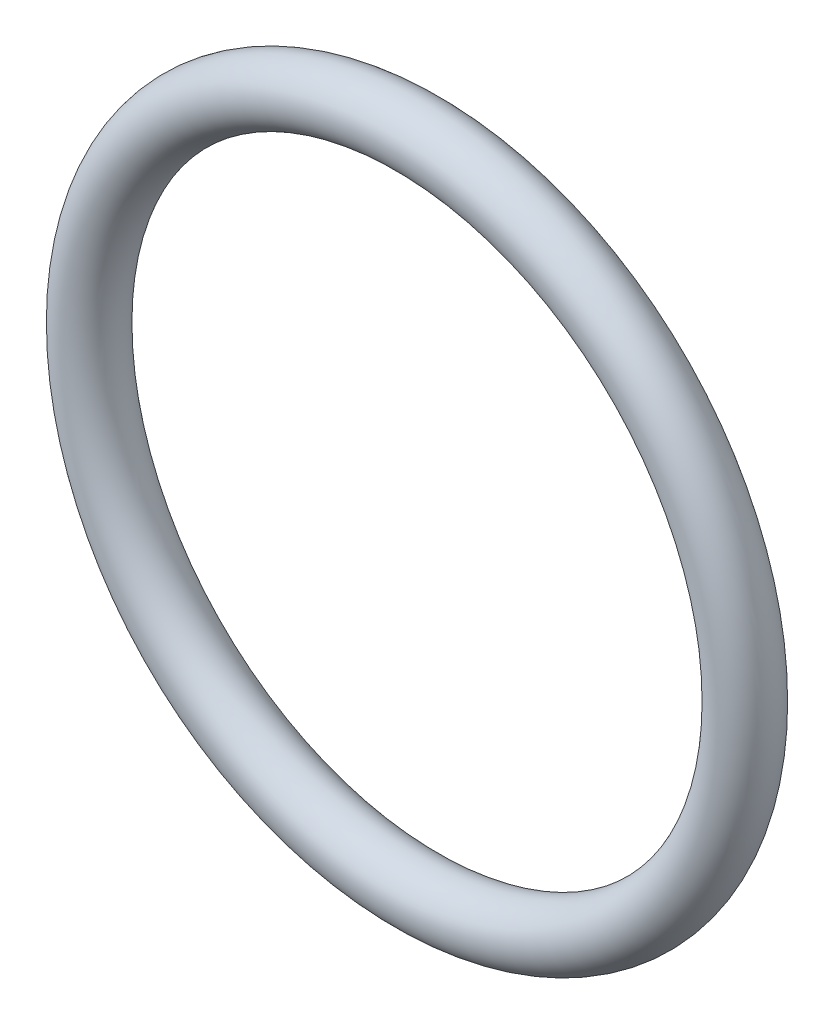
from build123d import *

# Parameters (mm, degrees)
SKETCH3_R = 1.5


with BuildPart() as part:
    # Sketch3 → Revolve1 (revolve)
    with BuildSketch(Plane(origin=(0, 0, 0), x_dir=(1, 0, 0), z_dir=(0, 1, 0))):
        with Locations((-16.25, 0)):
            Circle(SKETCH3_R)
    revolve(axis=Axis((0, 0, -1.5), (0, 0, 1)))


solid = part.part
